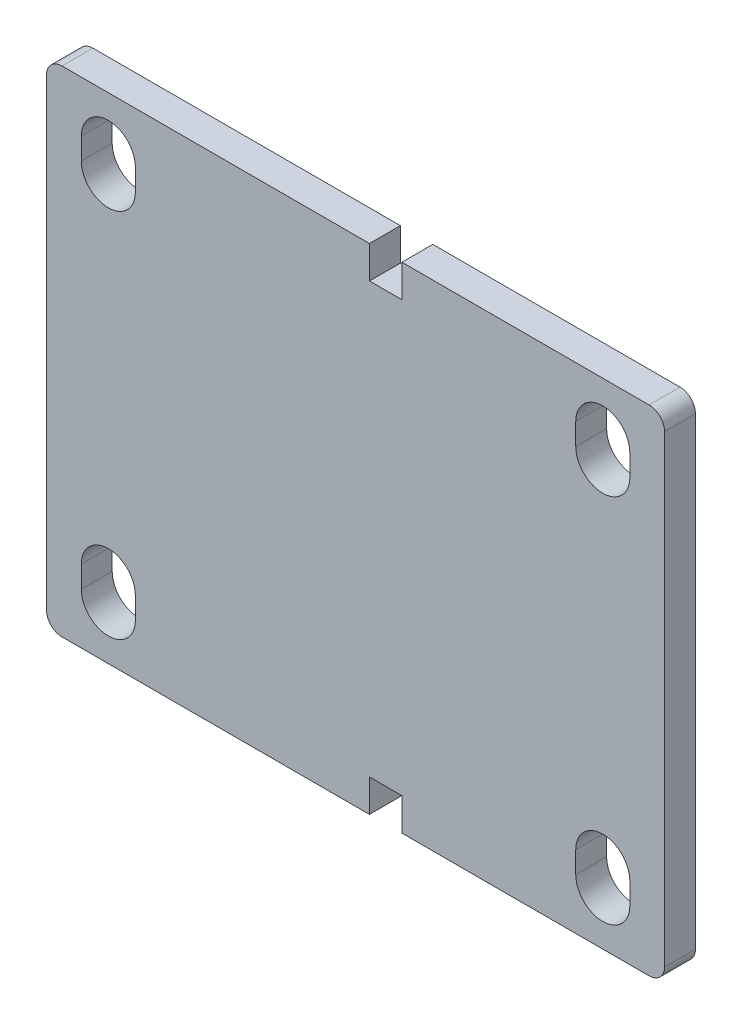
from build123d import *

# Parameters (mm, degrees)
ESQUISSE1_W             = 200
ESQUISSE1_H             = 160
ESQUISSE1_R             = 8.75
BOSS_EXTRU_1_DEPTH      = 10
ESQUISSE2_W             = 10.5
ESQUISSE2_H             = 10.5
ENL_V_MAT_EXTRU_1_DEPTH = 10
CONG_1_R                = 5
ENL_V_MAT_EXTRU_2_DEPTH = 11
SYM_TRIE2_COPY_1_DEPTH  = 11


with BuildPart() as part:
    # Esquisse1 → Boss.-Extru.1 (new body)
    with BuildSketch(Plane.XY):
        Rectangle(ESQUISSE1_W, ESQUISSE1_H)
        with Locations((-80, 60)):
            Circle(ESQUISSE1_R, mode=Mode.SUBTRACT)
        with Locations((80, 60)):
            Circle(ESQUISSE1_R, mode=Mode.SUBTRACT)
        with Locations((80, -60)):
            Circle(ESQUISSE1_R, mode=Mode.SUBTRACT)
        with Locations((-80, -60)):
            Circle(ESQUISSE1_R, mode=Mode.SUBTRACT)
    extrude(amount=BOSS_EXTRU_1_DEPTH)

    # Esquisse2 → Enlèv. mat.-Extru.1 (cut)
    with BuildSketch(Plane.XY.offset(10)):
        with Locations((9.75, 74.75)):
            Rectangle(ESQUISSE2_W, ESQUISSE2_H)
        with Locations((9.75, -74.75)):
            Rectangle(ESQUISSE2_W, ESQUISSE2_H)
    extrude(amount=-ENL_V_MAT_EXTRU_1_DEPTH, mode=Mode.SUBTRACT)

    # Congé1
    cong_1_edges = [part.edges().sort_by_distance(p)[0] for p in [
        (-100, 80, 5),
        (100, 80, 5),
        (100, -80, 5),
        (-100, -80, 5),
    ]]
    fillet(cong_1_edges, radius=CONG_1_R)

    # Esquisse3 → Enlèv. mat.-Extru.2 (cut, through all)
    with BuildSketch(Plane.XY.offset(10)):
        with BuildLine():
            Line((-71.25, 63.5), (-71.25, 56.5))
            ThreePointArc((-71.25, 56.5), (-80, 47.75), (-88.75, 56.5))
            Line((-88.75, 56.5), (-88.75, 63.5))
            ThreePointArc((-88.75, 63.5), (-80, 72.25), (-71.25, 63.5))
        make_face()
    enl_v_mat_extru_2 = extrude(amount=-ENL_V_MAT_EXTRU_2_DEPTH, mode=Mode.SUBTRACT)

    # Symétrie1: Enlèv. mat.-Extru.2 across plane
    add(enl_v_mat_extru_2.mirror(Plane.ZX), mode=Mode.SUBTRACT)

    # Symétrie2: Enlèv. mat.-Extru.2 across plane
    add(enl_v_mat_extru_2.mirror(Plane(origin=(0, 0, 0), x_dir=(0, 0, 1), z_dir=(1, 0, 0))), mode=Mode.SUBTRACT)

    # Symétrie2 copy 1 sketch → Symétrie2 copy 1 (cut, through all)
    with BuildSketch(Plane(origin=(0, 0, 10), x_dir=(-1, 0, 0), z_dir=(0, 0, 1))):
        with BuildLine():
            Line((-71.25, 63.5), (-71.25, 56.5))
            ThreePointArc((-71.25, 56.5), (-80, 47.75), (-88.75, 56.5))
            Line((-88.75, 56.5), (-88.75, 63.5))
            ThreePointArc((-88.75, 63.5), (-80, 72.25), (-71.25, 63.5))
        make_face()
    extrude(amount=-SYM_TRIE2_COPY_1_DEPTH, mode=Mode.SUBTRACT)


solid = part.part
